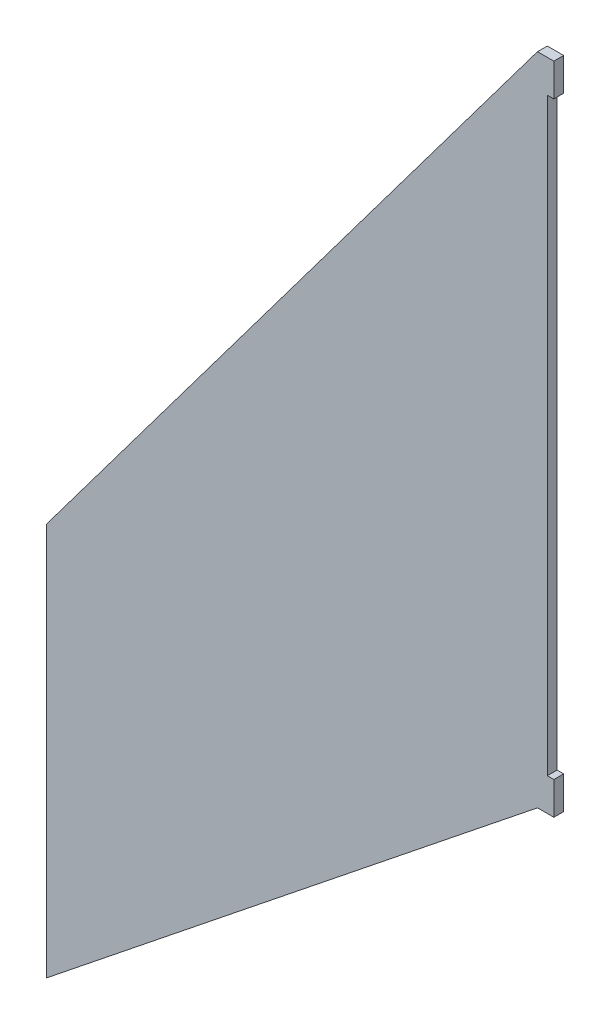
from build123d import *

# Parameters (mm, degrees)
BOSS_EXTRU_1_DEPTH = 3


with BuildPart() as part:
    # Esquisse1 → Boss.-Extru.1 (new body)
    with BuildSketch(Plane.XY):
        Polygon((0, 0), (-5, 0), (-155, -200), (-155, -320), (-5, -200), (0, -200), (0, -190), (-2, -190), (-2, -10), (0, -10), align=None)
    extrude(amount=BOSS_EXTRU_1_DEPTH)


solid = part.part
